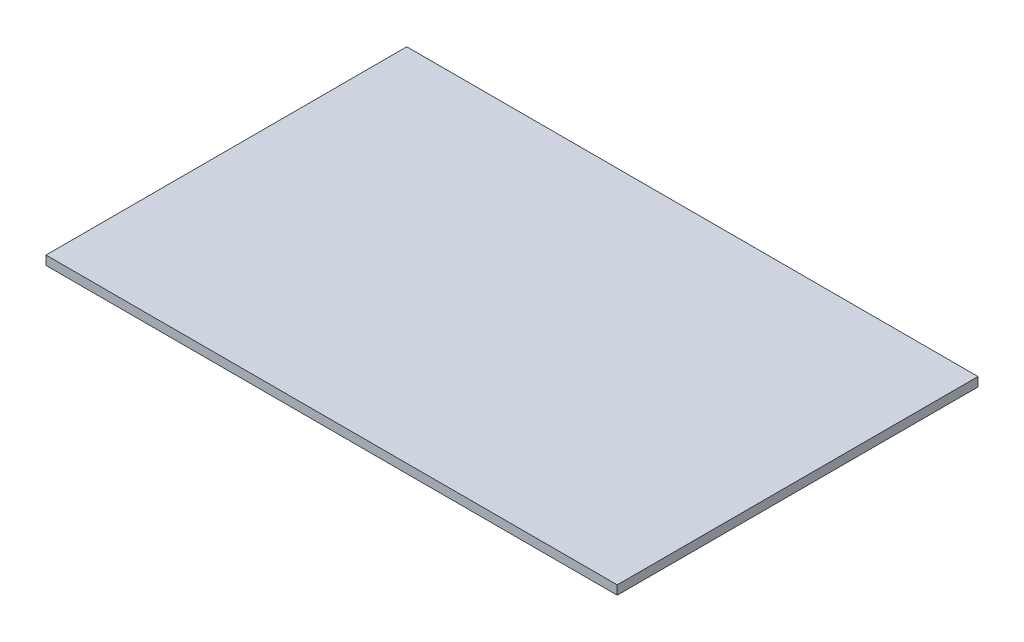
from build123d import *

# Parameters (mm, degrees)
SKETCH1_W           = 190
SKETCH1_H           = 120
BOSS_EXTRUDE1_DEPTH = 3


with BuildPart() as part:
    # Sketch1 → Boss-Extrude1 (new body)
    with BuildSketch(Plane(origin=(0, 0, 0), x_dir=(1, 0, 0), z_dir=(0, 1, 0))):
        with Locations((95, 60)):
            Rectangle(SKETCH1_W, SKETCH1_H)
    extrude(amount=BOSS_EXTRUDE1_DEPTH)


solid = part.part
